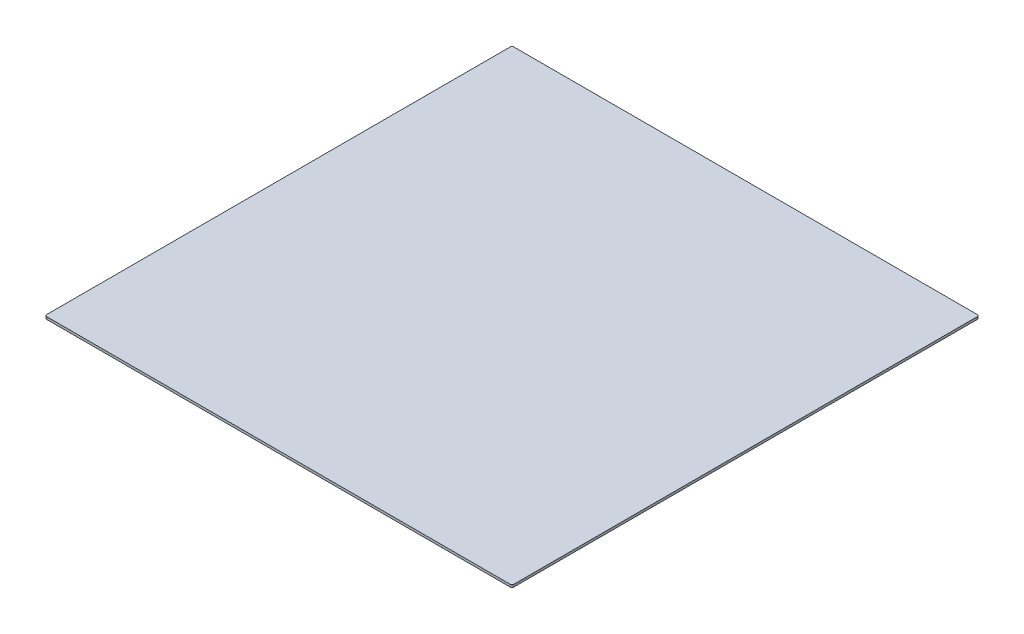
from build123d import *

# Parameters (mm, degrees)
SKETCH1_W           = 2438.4
SKETCH1_H           = 2438.4
BOSS_EXTRUDE1_DEPTH = 12.7
FILLET1_R           = 10


with BuildPart() as part:
    # Sketch1 → Boss-Extrude1 (new body)
    with BuildSketch(Plane(origin=(0, 0, 0), x_dir=(1, 0, 0), z_dir=(0, 1, 0))):
        Rectangle(SKETCH1_W, SKETCH1_H)
    extrude(amount=BOSS_EXTRUDE1_DEPTH)

    # Fillet1
    fillet1_edges = [part.edges().sort_by_distance(p)[0] for p in [
        (1219.2, 6.35, 1219.2),
        (-1219.2, 6.35, 1219.2),
        (-1219.2, 6.35, -1219.2),
        (1219.2, 6.35, -1219.2),
    ]]
    fillet(fillet1_edges, radius=FILLET1_R)


solid = part.part
